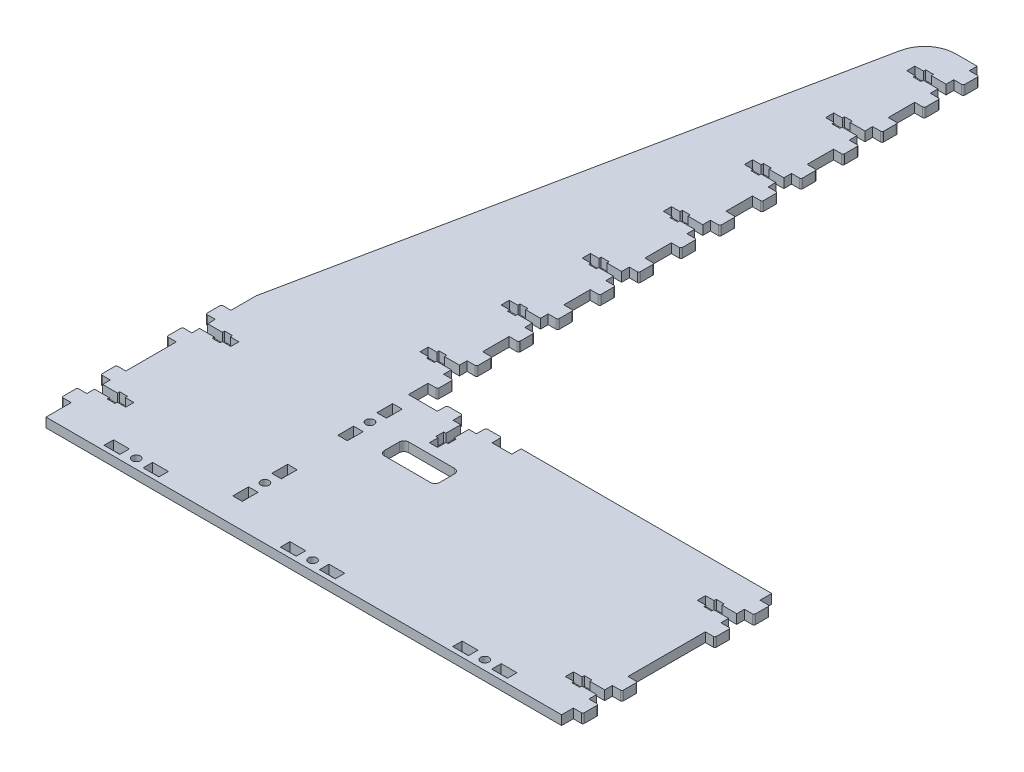
from build123d import *

# Parameters (mm, degrees)
BOSS_EXTRUDE1_DEPTH        = 6
M5_CLEARANCE_HOLE2_D       = 5.3
SKETCH240_W                = 66.1
SKETCH240_H                = 6
CUT_EXTRUDE1_DEPTH         = 7
SKETCH241_W                = 35.4
SKETCH241_H                = 15.5
CUT_EXTRUDE2_DEPTH         = 7
FILLET1_R                  = 3
SKETCH73_W                 = 6.1
SKETCH73_H                 = 10.1
CUT_EXTRUDE25_DEPTH        = 4
CUT_EXTRUDE25_DEPTH_BACK   = 4
SKETCH74_W                 = 6.1
SKETCH74_H                 = 10.1
CUT_EXTRUDE26_DEPTH        = 4
CUT_EXTRUDE26_DEPTH_BACK   = 4
SKETCH75_W                 = 6.1
SKETCH75_H                 = 10.1
CUT_EXTRUDE27_DEPTH        = 4
CUT_EXTRUDE27_DEPTH_BACK   = 4
CUT_EXTRUDE212_DEPTH       = 4
CUT_EXTRUDE212_DEPTH_BACK  = 4
SKETCH2345_W               = 6.1
SKETCH2345_H               = 10
BOSS_EXTRUDE23_DEPTH       = 3
BOSS_EXTRUDE23_DEPTH_BACK  = 3
FILLET14_R                 = 1
CUT_EXTRUDE213_DEPTH       = 4
CUT_EXTRUDE213_DEPTH_BACK  = 4
SKETCH2346_W               = 6.1
SKETCH2346_H               = 10
BOSS_EXTRUDE24_DEPTH       = 3
BOSS_EXTRUDE24_DEPTH_BACK  = 3
FILLET15_R                 = 1
CUT_EXTRUDE218_DEPTH       = 4
CUT_EXTRUDE218_DEPTH_BACK  = 4
SKETCH23415_W              = 6.1
SKETCH23415_H              = 10
BOSS_EXTRUDE29_DEPTH       = 3
BOSS_EXTRUDE29_DEPTH_BACK  = 3
FILLET110_R                = 1
CUT_EXTRUDE219_DEPTH       = 4
CUT_EXTRUDE219_DEPTH_BACK  = 4
SKETCH23416_W              = 6.1
SKETCH23416_H              = 10
BOSS_EXTRUDE210_DEPTH      = 3
BOSS_EXTRUDE210_DEPTH_BACK = 3
FILLET111_R                = 1
SKETCH78_W                 = 6.1
SKETCH78_H                 = 10.1
CUT_EXTRUDE224_DEPTH       = 4
CUT_EXTRUDE224_DEPTH_BACK  = 4
SKETCH79_W                 = 6.1
SKETCH79_H                 = 10.1
CUT_EXTRUDE225_DEPTH       = 4
CUT_EXTRUDE225_DEPTH_BACK  = 4
CUT_EXTRUDE238_DEPTH       = 4
CUT_EXTRUDE238_DEPTH_BACK  = 4
SKETCH23441_W              = 6.1
SKETCH23441_H              = 10
BOSS_EXTRUDE223_DEPTH      = 3
BOSS_EXTRUDE223_DEPTH_BACK = 3
FILLET124_R                = 1
CUT_EXTRUDE239_DEPTH       = 4
CUT_EXTRUDE239_DEPTH_BACK  = 4
SKETCH23442_W              = 6.1
SKETCH23442_H              = 10
BOSS_EXTRUDE224_DEPTH      = 3
BOSS_EXTRUDE224_DEPTH_BACK = 3
FILLET125_R                = 1
CUT_EXTRUDE240_DEPTH       = 4
CUT_EXTRUDE240_DEPTH_BACK  = 4
SKETCH23444_W              = 6.1
SKETCH23444_H              = 10
BOSS_EXTRUDE225_DEPTH      = 3
BOSS_EXTRUDE225_DEPTH_BACK = 3
FILLET126_R                = 1
CUT_EXTRUDE241_DEPTH       = 4
CUT_EXTRUDE241_DEPTH_BACK  = 4
SKETCH23446_W              = 6.1
SKETCH23446_H              = 10
BOSS_EXTRUDE226_DEPTH      = 3
BOSS_EXTRUDE226_DEPTH_BACK = 3
FILLET127_R                = 1
CUT_EXTRUDE242_DEPTH       = 4
CUT_EXTRUDE242_DEPTH_BACK  = 4
SKETCH23448_W              = 6.1
SKETCH23448_H              = 10
BOSS_EXTRUDE227_DEPTH      = 3
BOSS_EXTRUDE227_DEPTH_BACK = 3
FILLET128_R                = 1
CUT_EXTRUDE243_DEPTH       = 4
CUT_EXTRUDE243_DEPTH_BACK  = 4
SKETCH23450_W              = 6.1
SKETCH23450_H              = 10
BOSS_EXTRUDE228_DEPTH      = 3
BOSS_EXTRUDE228_DEPTH_BACK = 3
FILLET129_R                = 1
CUT_EXTRUDE247_DEPTH       = 4
CUT_EXTRUDE247_DEPTH_BACK  = 4
SKETCH23458_W              = 6.1
SKETCH23458_H              = 10
BOSS_EXTRUDE232_DEPTH      = 3
BOSS_EXTRUDE232_DEPTH_BACK = 3
FILLET133_R                = 1
FILLET134_R                = 20
CUT_EXTRUDE251_DEPTH       = 4
CUT_EXTRUDE251_DEPTH_BACK  = 4
SKETCH23465_W              = 6.1
SKETCH23465_H              = 10
BOSS_EXTRUDE235_DEPTH      = 3
BOSS_EXTRUDE235_DEPTH_BACK = 3
FILLET138_R                = 1


with BuildPart() as part:
    # Sketch1 → Boss-Extrude1 (new body)
    with BuildSketch(Plane(origin=(0, 0, 0), x_dir=(1, 0, 0), z_dir=(0, 1, 0))):
        Polygon((0, 0), (0, 134.5), (73.5, 492.5), (103.5, 492.5), (103.5, 134.5), (330, 134.5), (330, 0), align=None)
    extrude(amount=BOSS_EXTRUDE1_DEPTH)

    # M5 Clearance Hole2 (through all)
    with Locations(Plane(origin=(0, 6, 0), x_dir=(1, 0, 0), z_dir=(0, 1, 0))):
        with Locations((51.75, 6), (164.625, 6), (274.875, 6), (106.5, 33.625), (106.5, 100.875)):
            Hole(M5_CLEARANCE_HOLE2_D / 2)

    # Sketch240 → Cut-Extrude1 (cut, through all)
    with BuildSketch(Plane(origin=(0, 6, 0), x_dir=(1, 0, 0), z_dir=(0, 1, 0))):
        with Locations((136.55, 131.5)):
            Rectangle(SKETCH240_W, SKETCH240_H)
    extrude(amount=-CUT_EXTRUDE1_DEPTH, mode=Mode.SUBTRACT)

    # Sketch241 → Cut-Extrude2 (cut, through all)
    with BuildSketch(Plane(origin=(0, 6, 0), x_dir=(1, 0, 0), z_dir=(0, 1, 0))):
        with Locations((144.5, 94.55)):
            Rectangle(SKETCH241_W, SKETCH241_H)
    extrude(amount=-CUT_EXTRUDE2_DEPTH, mode=Mode.SUBTRACT)

    # Fillet1
    fillet1_edges = [part.edges().sort_by_distance(p)[0] for p in [
        (126.8, 3, -86.8),
        (126.8, 3, -102.3),
        (162.2, 3, -102.3),
        (162.2, 3, -86.8),
    ]]
    fillet(fillet1_edges, radius=FILLET1_R)

    # Sketch73 → Cut-Extrude25 (cut, two sides)
    with BuildSketch(Plane(origin=(71.75, 3, 38), x_dir=(0, 0, -1), z_dir=(0, -1, 0))) as cut_extrude25_sk:
        with Locations((44, -32.5)):
            Rectangle(SKETCH73_W, SKETCH73_H)
        with Locations((44, -7.5)):
            Rectangle(SKETCH73_W, SKETCH73_H)
    extrude(amount=CUT_EXTRUDE25_DEPTH, mode=Mode.SUBTRACT)
    extrude(cut_extrude25_sk.sketch, amount=-CUT_EXTRUDE25_DEPTH_BACK, mode=Mode.SUBTRACT)

    # Sketch74 → Cut-Extrude26 (cut, two sides)
    with BuildSketch(Plane(origin=(184.625, 3, 38), x_dir=(0, 0, -1), z_dir=(0, -1, 0))) as cut_extrude26_sk:
        with Locations((44, -32.5)):
            Rectangle(SKETCH74_W, SKETCH74_H)
        with Locations((44, -7.5)):
            Rectangle(SKETCH74_W, SKETCH74_H)
    extrude(amount=CUT_EXTRUDE26_DEPTH, mode=Mode.SUBTRACT)
    extrude(cut_extrude26_sk.sketch, amount=-CUT_EXTRUDE26_DEPTH_BACK, mode=Mode.SUBTRACT)

    # Sketch75 → Cut-Extrude27 (cut, two sides)
    with BuildSketch(Plane(origin=(294.875, 3, 38), x_dir=(0, 0, -1), z_dir=(0, -1, 0))) as cut_extrude27_sk:
        with Locations((44, -32.5)):
            Rectangle(SKETCH75_W, SKETCH75_H)
        with Locations((44, -7.5)):
            Rectangle(SKETCH75_W, SKETCH75_H)
    extrude(amount=CUT_EXTRUDE27_DEPTH, mode=Mode.SUBTRACT)
    extrude(cut_extrude27_sk.sketch, amount=-CUT_EXTRUDE27_DEPTH_BACK, mode=Mode.SUBTRACT)

    # Sketch2343 → Cut-Extrude212 (cut, two sides)
    with BuildSketch(Plane(origin=(50, 3, -80.875), x_dir=(-1, 0, 0), z_dir=(0, -1, 0))) as cut_extrude212_sk:
        Polygon((30, 17.4), (30, 22.6), (35.5, 22.6), (35.5, 24), (40.5, 24), (40.5, 22.6), (50, 22.6), (50, 17.4), (40.5, 17.4), (40.5, 16), (35.5, 16), (35.5, 17.4), align=None)
    extrude(amount=CUT_EXTRUDE212_DEPTH, mode=Mode.SUBTRACT)
    extrude(cut_extrude212_sk.sketch, amount=-CUT_EXTRUDE212_DEPTH_BACK, mode=Mode.SUBTRACT)

    # Sketch2345 → Boss-Extrude23 (add, two sides)
    with BuildSketch(Plane(origin=(50, 3, -80.875), x_dir=(-1, 0, 0), z_dir=(0, -1, 0))) as boss_extrude23_sk:
        with Locations((53.05, 32.5)):
            Rectangle(SKETCH2345_W, SKETCH2345_H)
        with Locations((53.05, 7.5)):
            Rectangle(SKETCH2345_W, SKETCH2345_H)
    extrude(amount=BOSS_EXTRUDE23_DEPTH)
    extrude(boss_extrude23_sk.sketch, amount=-BOSS_EXTRUDE23_DEPTH_BACK)

    # Fillet14
    fillet14_edges = [part.edges().sort_by_distance(p)[0] for p in [
        (-6.1, 3, -118.375),
        (-6.1, 3, -108.375),
        (-6.1, 3, -93.375),
        (-6.1, 3, -83.375),
    ]]
    fillet(fillet14_edges, radius=FILLET14_R)

    # Sketch2344 → Cut-Extrude213 (cut, two sides)
    with BuildSketch(Plane(origin=(50, 3, -13.625), x_dir=(-1, 0, 0), z_dir=(0, -1, 0))) as cut_extrude213_sk:
        Polygon((30, 17.4), (30, 22.6), (35.5, 22.6), (35.5, 24), (40.5, 24), (40.5, 22.6), (50, 22.6), (50, 17.4), (40.5, 17.4), (40.5, 16), (35.5, 16), (35.5, 17.4), align=None)
    extrude(amount=CUT_EXTRUDE213_DEPTH, mode=Mode.SUBTRACT)
    extrude(cut_extrude213_sk.sketch, amount=-CUT_EXTRUDE213_DEPTH_BACK, mode=Mode.SUBTRACT)

    # Sketch2346 → Boss-Extrude24 (add, two sides)
    with BuildSketch(Plane(origin=(50, 3, -13.625), x_dir=(-1, 0, 0), z_dir=(0, -1, 0))) as boss_extrude24_sk:
        with Locations((53.05, 32.5)):
            Rectangle(SKETCH2346_W, SKETCH2346_H)
        with Locations((53.05, 7.5)):
            Rectangle(SKETCH2346_W, SKETCH2346_H)
    extrude(amount=BOSS_EXTRUDE24_DEPTH)
    extrude(boss_extrude24_sk.sketch, amount=-BOSS_EXTRUDE24_DEPTH_BACK)

    # Fillet15
    fillet15_edges = [part.edges().sort_by_distance(p)[0] for p in [
        (-6.1, 3, -51.125),
        (-6.1, 3, -41.125),
        (-6.1, 3, -26.125),
        (-6.1, 3, -16.125),
    ]]
    fillet(fillet15_edges, radius=FILLET15_R)

    # Sketch23413 → Cut-Extrude218 (cut, two sides)
    with BuildSketch(Plane(origin=(280, 3, -89.5), x_dir=(1, 0, 0), z_dir=(0, 1, 0))) as cut_extrude218_sk:
        Polygon((30, 17.4), (30, 22.6), (35.5, 22.6), (35.5, 24), (40.5, 24), (40.5, 22.6), (50, 22.6), (50, 17.4), (40.5, 17.4), (40.5, 16), (35.5, 16), (35.5, 17.4), align=None)
    extrude(amount=CUT_EXTRUDE218_DEPTH, mode=Mode.SUBTRACT)
    extrude(cut_extrude218_sk.sketch, amount=-CUT_EXTRUDE218_DEPTH_BACK, mode=Mode.SUBTRACT)

    # Sketch23415 → Boss-Extrude29 (add, two sides)
    with BuildSketch(Plane(origin=(280, 3, -89.5), x_dir=(1, 0, 0), z_dir=(0, 1, 0))) as boss_extrude29_sk:
        with Locations((53.05, 32.5)):
            Rectangle(SKETCH23415_W, SKETCH23415_H)
        with Locations((53.05, 7.5)):
            Rectangle(SKETCH23415_W, SKETCH23415_H)
    extrude(amount=BOSS_EXTRUDE29_DEPTH)
    extrude(boss_extrude29_sk.sketch, amount=-BOSS_EXTRUDE29_DEPTH_BACK)

    # Fillet110
    fillet110_edges = [part.edges().sort_by_distance(p)[0] for p in [
        (336.1, 3, -127),
        (336.1, 3, -117),
        (336.1, 3, -102),
        (336.1, 3, -92),
    ]]
    fillet(fillet110_edges, radius=FILLET110_R)

    # Sketch23414 → Cut-Extrude219 (cut, two sides)
    with BuildSketch(Plane(origin=(280, 3, -5), x_dir=(1, 0, 0), z_dir=(0, 1, 0))) as cut_extrude219_sk:
        Polygon((30, 17.4), (30, 22.6), (35.5, 22.6), (35.5, 24), (40.5, 24), (40.5, 22.6), (50, 22.6), (50, 17.4), (40.5, 17.4), (40.5, 16), (35.5, 16), (35.5, 17.4), align=None)
    extrude(amount=CUT_EXTRUDE219_DEPTH, mode=Mode.SUBTRACT)
    extrude(cut_extrude219_sk.sketch, amount=-CUT_EXTRUDE219_DEPTH_BACK, mode=Mode.SUBTRACT)

    # Sketch23416 → Boss-Extrude210 (add, two sides)
    with BuildSketch(Plane(origin=(280, 3, -5), x_dir=(1, 0, 0), z_dir=(0, 1, 0))) as boss_extrude210_sk:
        with Locations((53.05, 32.5)):
            Rectangle(SKETCH23416_W, SKETCH23416_H)
        with Locations((53.05, 7.5)):
            Rectangle(SKETCH23416_W, SKETCH23416_H)
    extrude(amount=BOSS_EXTRUDE210_DEPTH)
    extrude(boss_extrude210_sk.sketch, amount=-BOSS_EXTRUDE210_DEPTH_BACK)

    # Fillet111
    fillet111_edges = [part.edges().sort_by_distance(p)[0] for p in [
        (336.1, 3, -42.5),
        (336.1, 3, -32.5),
        (336.1, 3, -17.5),
        (336.1, 3, -7.5),
    ]]
    fillet(fillet111_edges, radius=FILLET111_R)

    # Sketch78 → Cut-Extrude224 (cut, two sides)
    with BuildSketch(Plane(origin=(62.5, 3, -120.875), x_dir=(1, 0, 0), z_dir=(0, 1, 0))) as cut_extrude224_sk:
        with Locations((44, -32.5)):
            Rectangle(SKETCH78_W, SKETCH78_H)
        with Locations((44, -7.5)):
            Rectangle(SKETCH78_W, SKETCH78_H)
    extrude(amount=CUT_EXTRUDE224_DEPTH, mode=Mode.SUBTRACT)
    extrude(cut_extrude224_sk.sketch, amount=-CUT_EXTRUDE224_DEPTH_BACK, mode=Mode.SUBTRACT)

    # Sketch79 → Cut-Extrude225 (cut, two sides)
    with BuildSketch(Plane(origin=(62.5, 3, -53.625), x_dir=(1, 0, 0), z_dir=(0, 1, 0))) as cut_extrude225_sk:
        with Locations((44, -32.5)):
            Rectangle(SKETCH79_W, SKETCH79_H)
        with Locations((44, -7.5)):
            Rectangle(SKETCH79_W, SKETCH79_H)
    extrude(amount=CUT_EXTRUDE225_DEPTH, mode=Mode.SUBTRACT)
    extrude(cut_extrude225_sk.sketch, amount=-CUT_EXTRUDE225_DEPTH_BACK, mode=Mode.SUBTRACT)

    # Sketch23439 → Cut-Extrude238 (cut, two sides)
    with BuildSketch(Plane(origin=(53.5, 3, -138.5), x_dir=(1, 0, 0), z_dir=(0, 1, 0))) as cut_extrude238_sk:
        Polygon((30, 17.4), (30, 22.6), (35.5, 22.6), (35.5, 24), (40.5, 24), (40.5, 22.6), (50, 22.6), (50, 17.4), (40.5, 17.4), (40.5, 16), (35.5, 16), (35.5, 17.4), align=None)
    extrude(amount=CUT_EXTRUDE238_DEPTH, mode=Mode.SUBTRACT)
    extrude(cut_extrude238_sk.sketch, amount=-CUT_EXTRUDE238_DEPTH_BACK, mode=Mode.SUBTRACT)

    # Sketch23441 → Boss-Extrude223 (add, two sides)
    with BuildSketch(Plane(origin=(53.5, 3, -138.5), x_dir=(1, 0, 0), z_dir=(0, 1, 0))) as boss_extrude223_sk:
        with Locations((53.05, 32.5)):
            Rectangle(SKETCH23441_W, SKETCH23441_H)
        with Locations((53.05, 7.5)):
            Rectangle(SKETCH23441_W, SKETCH23441_H)
    extrude(amount=BOSS_EXTRUDE223_DEPTH)
    extrude(boss_extrude223_sk.sketch, amount=-BOSS_EXTRUDE223_DEPTH_BACK)

    # Fillet124
    fillet124_edges = [part.edges().sort_by_distance(p)[0] for p in [
        (109.6, 3, -176),
        (109.6, 3, -166),
        (109.6, 3, -151),
        (109.6, 3, -141),
    ]]
    fillet(fillet124_edges, radius=FILLET124_R)

    # Sketch23440 → Cut-Extrude239 (cut, two sides)
    with BuildSketch(Plane(origin=(53.5, 3, -190.416666667), x_dir=(1, 0, 0), z_dir=(0, 1, 0))) as cut_extrude239_sk:
        Polygon((30, 17.4), (30, 22.6), (35.5, 22.6), (35.5, 24), (40.5, 24), (40.5, 22.6), (50, 22.6), (50, 17.4), (40.5, 17.4), (40.5, 16), (35.5, 16), (35.5, 17.4), align=None)
    extrude(amount=CUT_EXTRUDE239_DEPTH, mode=Mode.SUBTRACT)
    extrude(cut_extrude239_sk.sketch, amount=-CUT_EXTRUDE239_DEPTH_BACK, mode=Mode.SUBTRACT)

    # Sketch23442 → Boss-Extrude224 (add, two sides)
    with BuildSketch(Plane(origin=(53.5, 3, -190.416666667), x_dir=(1, 0, 0), z_dir=(0, 1, 0))) as boss_extrude224_sk:
        with Locations((53.05, 32.5)):
            Rectangle(SKETCH23442_W, SKETCH23442_H)
        with Locations((53.05, 7.5)):
            Rectangle(SKETCH23442_W, SKETCH23442_H)
    extrude(amount=BOSS_EXTRUDE224_DEPTH)
    extrude(boss_extrude224_sk.sketch, amount=-BOSS_EXTRUDE224_DEPTH_BACK)

    # Fillet125
    fillet125_edges = [part.edges().sort_by_distance(p)[0] for p in [
        (109.6, 3, -227.916666667),
        (109.6, 3, -217.916666667),
        (109.6, 3, -202.916666667),
        (109.6, 3, -192.916666667),
    ]]
    fillet(fillet125_edges, radius=FILLET125_R)

    # Sketch23443 → Cut-Extrude240 (cut, two sides)
    with BuildSketch(Plane(origin=(53.5, 3, -242.333333333), x_dir=(1, 0, 0), z_dir=(0, 1, 0))) as cut_extrude240_sk:
        Polygon((30, 17.4), (30, 22.6), (35.5, 22.6), (35.5, 24), (40.5, 24), (40.5, 22.6), (50, 22.6), (50, 17.4), (40.5, 17.4), (40.5, 16), (35.5, 16), (35.5, 17.4), align=None)
    extrude(amount=CUT_EXTRUDE240_DEPTH, mode=Mode.SUBTRACT)
    extrude(cut_extrude240_sk.sketch, amount=-CUT_EXTRUDE240_DEPTH_BACK, mode=Mode.SUBTRACT)

    # Sketch23444 → Boss-Extrude225 (add, two sides)
    with BuildSketch(Plane(origin=(53.5, 3, -242.333333333), x_dir=(1, 0, 0), z_dir=(0, 1, 0))) as boss_extrude225_sk:
        with Locations((53.05, 32.5)):
            Rectangle(SKETCH23444_W, SKETCH23444_H)
        with Locations((53.05, 7.5)):
            Rectangle(SKETCH23444_W, SKETCH23444_H)
    extrude(amount=BOSS_EXTRUDE225_DEPTH)
    extrude(boss_extrude225_sk.sketch, amount=-BOSS_EXTRUDE225_DEPTH_BACK)

    # Fillet126
    fillet126_edges = [part.edges().sort_by_distance(p)[0] for p in [
        (109.6, 3, -279.833333333),
        (109.6, 3, -269.833333333),
        (109.6, 3, -254.833333333),
        (109.6, 3, -244.833333333),
    ]]
    fillet(fillet126_edges, radius=FILLET126_R)

    # Sketch23445 → Cut-Extrude241 (cut, two sides)
    with BuildSketch(Plane(origin=(53.5, 3, -294.25), x_dir=(1, 0, 0), z_dir=(0, 1, 0))) as cut_extrude241_sk:
        Polygon((30, 17.4), (30, 22.6), (35.5, 22.6), (35.5, 24), (40.5, 24), (40.5, 22.6), (50, 22.6), (50, 17.4), (40.5, 17.4), (40.5, 16), (35.5, 16), (35.5, 17.4), align=None)
    extrude(amount=CUT_EXTRUDE241_DEPTH, mode=Mode.SUBTRACT)
    extrude(cut_extrude241_sk.sketch, amount=-CUT_EXTRUDE241_DEPTH_BACK, mode=Mode.SUBTRACT)

    # Sketch23446 → Boss-Extrude226 (add, two sides)
    with BuildSketch(Plane(origin=(53.5, 3, -294.25), x_dir=(1, 0, 0), z_dir=(0, 1, 0))) as boss_extrude226_sk:
        with Locations((53.05, 32.5)):
            Rectangle(SKETCH23446_W, SKETCH23446_H)
        with Locations((53.05, 7.5)):
            Rectangle(SKETCH23446_W, SKETCH23446_H)
    extrude(amount=BOSS_EXTRUDE226_DEPTH)
    extrude(boss_extrude226_sk.sketch, amount=-BOSS_EXTRUDE226_DEPTH_BACK)

    # Fillet127
    fillet127_edges = [part.edges().sort_by_distance(p)[0] for p in [
        (109.6, 3, -331.75),
        (109.6, 3, -321.75),
        (109.6, 3, -306.75),
        (109.6, 3, -296.75),
    ]]
    fillet(fillet127_edges, radius=FILLET127_R)

    # Sketch23447 → Cut-Extrude242 (cut, two sides)
    with BuildSketch(Plane(origin=(53.5, 3, -346.166666667), x_dir=(1, 0, 0), z_dir=(0, 1, 0))) as cut_extrude242_sk:
        Polygon((30, 17.4), (30, 22.6), (35.5, 22.6), (35.5, 24), (40.5, 24), (40.5, 22.6), (50, 22.6), (50, 17.4), (40.5, 17.4), (40.5, 16), (35.5, 16), (35.5, 17.4), align=None)
    extrude(amount=CUT_EXTRUDE242_DEPTH, mode=Mode.SUBTRACT)
    extrude(cut_extrude242_sk.sketch, amount=-CUT_EXTRUDE242_DEPTH_BACK, mode=Mode.SUBTRACT)

    # Sketch23448 → Boss-Extrude227 (add, two sides)
    with BuildSketch(Plane(origin=(53.5, 3, -346.166666667), x_dir=(1, 0, 0), z_dir=(0, 1, 0))) as boss_extrude227_sk:
        with Locations((53.05, 32.5)):
            Rectangle(SKETCH23448_W, SKETCH23448_H)
        with Locations((53.05, 7.5)):
            Rectangle(SKETCH23448_W, SKETCH23448_H)
    extrude(amount=BOSS_EXTRUDE227_DEPTH)
    extrude(boss_extrude227_sk.sketch, amount=-BOSS_EXTRUDE227_DEPTH_BACK)

    # Fillet128
    fillet128_edges = [part.edges().sort_by_distance(p)[0] for p in [
        (109.6, 3, -383.666666667),
        (109.6, 3, -373.666666667),
        (109.6, 3, -358.666666667),
        (109.6, 3, -348.666666667),
    ]]
    fillet(fillet128_edges, radius=FILLET128_R)

    # Sketch23449 → Cut-Extrude243 (cut, two sides)
    with BuildSketch(Plane(origin=(53.5, 3, -398.083333333), x_dir=(1, 0, 0), z_dir=(0, 1, 0))) as cut_extrude243_sk:
        Polygon((30, 17.4), (30, 22.6), (35.5, 22.6), (35.5, 24), (40.5, 24), (40.5, 22.6), (50, 22.6), (50, 17.4), (40.5, 17.4), (40.5, 16), (35.5, 16), (35.5, 17.4), align=None)
    extrude(amount=CUT_EXTRUDE243_DEPTH, mode=Mode.SUBTRACT)
    extrude(cut_extrude243_sk.sketch, amount=-CUT_EXTRUDE243_DEPTH_BACK, mode=Mode.SUBTRACT)

    # Sketch23450 → Boss-Extrude228 (add, two sides)
    with BuildSketch(Plane(origin=(53.5, 3, -398.083333333), x_dir=(1, 0, 0), z_dir=(0, 1, 0))) as boss_extrude228_sk:
        with Locations((53.05, 32.5)):
            Rectangle(SKETCH23450_W, SKETCH23450_H)
        with Locations((53.05, 7.5)):
            Rectangle(SKETCH23450_W, SKETCH23450_H)
    extrude(amount=BOSS_EXTRUDE228_DEPTH)
    extrude(boss_extrude228_sk.sketch, amount=-BOSS_EXTRUDE228_DEPTH_BACK)

    # Fillet129
    fillet129_edges = [part.edges().sort_by_distance(p)[0] for p in [
        (109.6, 3, -435.583333333),
        (109.6, 3, -425.583333333),
        (109.6, 3, -410.583333333),
        (109.6, 3, -400.583333333),
    ]]
    fillet(fillet129_edges, radius=FILLET129_R)

    # Sketch23456 → Cut-Extrude247 (cut, two sides)
    with BuildSketch(Plane(origin=(53.5, 3, -450), x_dir=(1, 0, 0), z_dir=(0, 1, 0))) as cut_extrude247_sk:
        Polygon((30, 17.4), (30, 22.6), (35.5, 22.6), (35.5, 24), (40.5, 24), (40.5, 22.6), (50, 22.6), (50, 17.4), (40.5, 17.4), (40.5, 16), (35.5, 16), (35.5, 17.4), align=None)
    extrude(amount=CUT_EXTRUDE247_DEPTH, mode=Mode.SUBTRACT)
    extrude(cut_extrude247_sk.sketch, amount=-CUT_EXTRUDE247_DEPTH_BACK, mode=Mode.SUBTRACT)

    # Sketch23458 → Boss-Extrude232 (add, two sides)
    with BuildSketch(Plane(origin=(53.5, 3, -450), x_dir=(1, 0, 0), z_dir=(0, 1, 0))) as boss_extrude232_sk:
        with Locations((53.05, 32.5)):
            Rectangle(SKETCH23458_W, SKETCH23458_H)
        with Locations((53.05, 7.5)):
            Rectangle(SKETCH23458_W, SKETCH23458_H)
    extrude(amount=BOSS_EXTRUDE232_DEPTH)
    extrude(boss_extrude232_sk.sketch, amount=-BOSS_EXTRUDE232_DEPTH_BACK)

    # Fillet133
    fillet133_edges = [part.edges().sort_by_distance(p)[0] for p in [
        (109.6, 3, -487.5),
        (109.6, 3, -477.5),
        (109.6, 3, -462.5),
        (109.6, 3, -452.5),
    ]]
    fillet(fillet133_edges, radius=FILLET133_R)

    # Fillet134
    fillet134_edges = [part.edges().sort_by_distance(p)[0] for p in [
        (73.5, 3, -492.5),
    ]]
    fillet(fillet134_edges, radius=FILLET134_R)

    # Sketch23463 → Cut-Extrude251 (cut, two sides)
    with BuildSketch(Plane(origin=(159.5, 3, -78.5), x_dir=(0, 0, -1), z_dir=(0, 1, 0))) as cut_extrude251_sk:
        Polygon((30, 17.4), (30, 22.6), (35.5, 22.6), (35.5, 24), (40.5, 24), (40.5, 22.6), (50, 22.6), (50, 17.4), (40.5, 17.4), (40.5, 16), (35.5, 16), (35.5, 17.4), align=None)
    extrude(amount=CUT_EXTRUDE251_DEPTH, mode=Mode.SUBTRACT)
    extrude(cut_extrude251_sk.sketch, amount=-CUT_EXTRUDE251_DEPTH_BACK, mode=Mode.SUBTRACT)

    # Sketch23465 → Boss-Extrude235 (add, two sides)
    with BuildSketch(Plane(origin=(159.5, 3, -78.5), x_dir=(0, 0, -1), z_dir=(0, 1, 0))) as boss_extrude235_sk:
        with Locations((53.05, 32.5)):
            Rectangle(SKETCH23465_W, SKETCH23465_H)
        with Locations((53.05, 7.5)):
            Rectangle(SKETCH23465_W, SKETCH23465_H)
    extrude(amount=BOSS_EXTRUDE235_DEPTH)
    extrude(boss_extrude235_sk.sketch, amount=-BOSS_EXTRUDE235_DEPTH_BACK)

    # Fillet138
    fillet138_edges = [part.edges().sort_by_distance(p)[0] for p in [
        (122, 3, -134.6),
        (132, 3, -134.6),
        (147, 3, -134.6),
        (157, 3, -134.6),
    ]]
    fillet(fillet138_edges, radius=FILLET138_R)


solid = part.part
